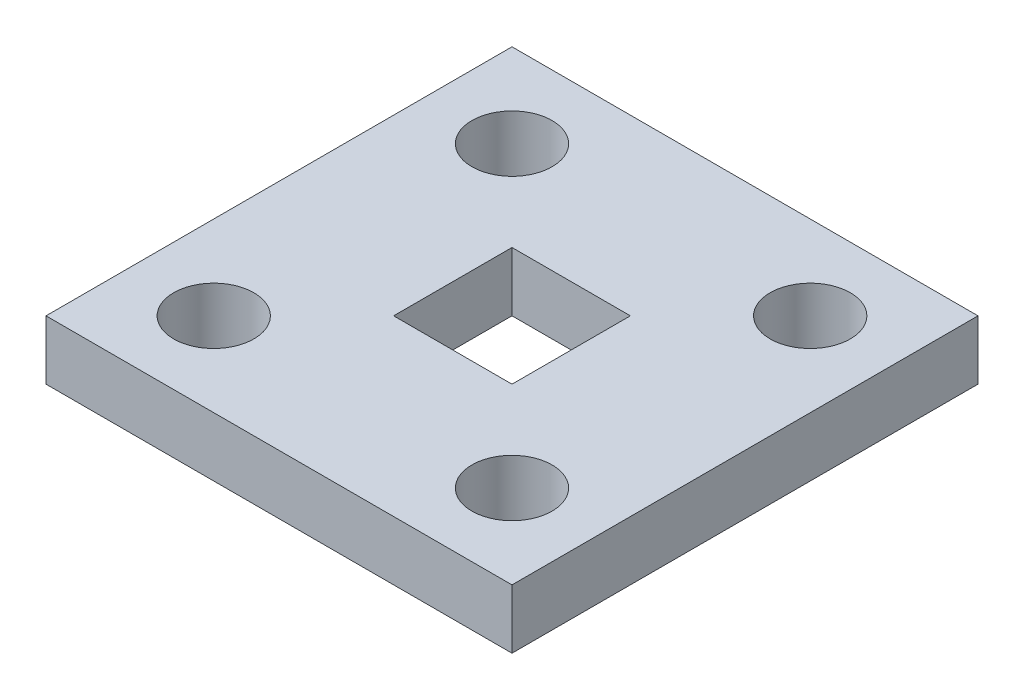
from build123d import *

# Parameters (mm, degrees)
SKETCH1_W           = 25
SKETCH1_H           = 25
SKETCH1_R           = 2.15
SKETCH1_W_2         = 6.35
SKETCH1_H_2         = 6.35
BOSS_EXTRUDE1_DEPTH = 3.175


with BuildPart() as part:
    # Sketch1 → Boss-Extrude1 (new body)
    with BuildSketch(Plane(origin=(0, 0, 0), x_dir=(1, 0, 0), z_dir=(0, 1, 0))):
        Rectangle(SKETCH1_W, SKETCH1_H)
        with Locations((-8, 8)):
            Circle(SKETCH1_R, mode=Mode.SUBTRACT)
        with Locations((8, 8)):
            Circle(SKETCH1_R, mode=Mode.SUBTRACT)
        with Locations((8, -8)):
            Circle(SKETCH1_R, mode=Mode.SUBTRACT)
        with Locations((-8, -8)):
            Circle(SKETCH1_R, mode=Mode.SUBTRACT)
        Rectangle(SKETCH1_W_2, SKETCH1_H_2, mode=Mode.SUBTRACT)
    extrude(amount=BOSS_EXTRUDE1_DEPTH)


solid = part.part
